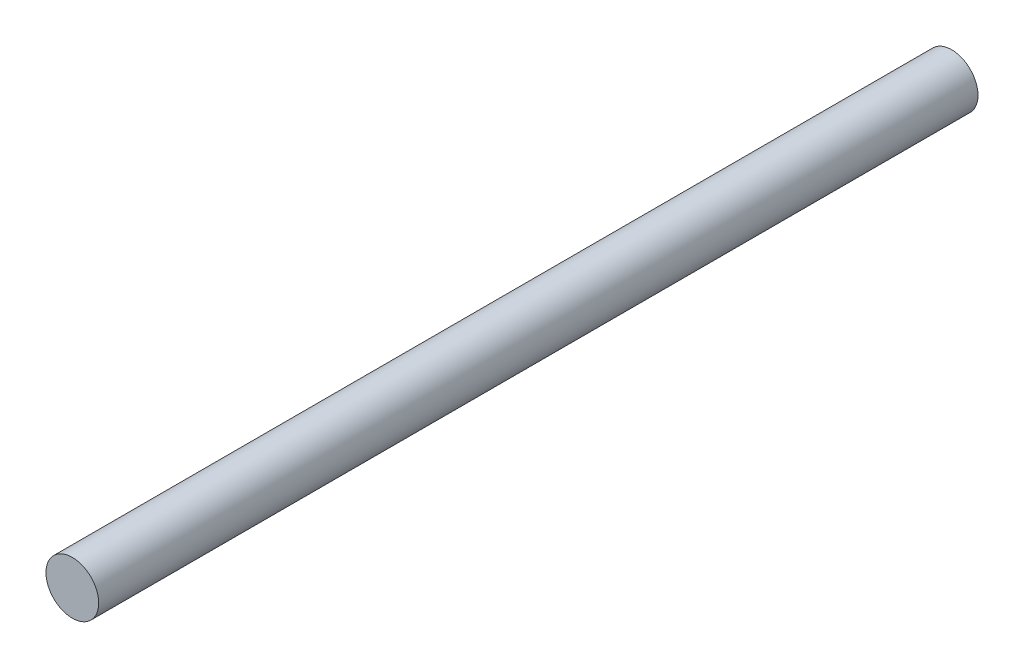
from build123d import *

# Parameters (mm, degrees)
SKETCH1_R           = 1.5
BOSS_EXTRUDE1_DEPTH = 50


with BuildPart() as part:
    # Sketch1 → Boss-Extrude1 (new body)
    with BuildSketch(Plane.XY):
        Circle(SKETCH1_R)
    extrude(amount=BOSS_EXTRUDE1_DEPTH)


solid = part.part
